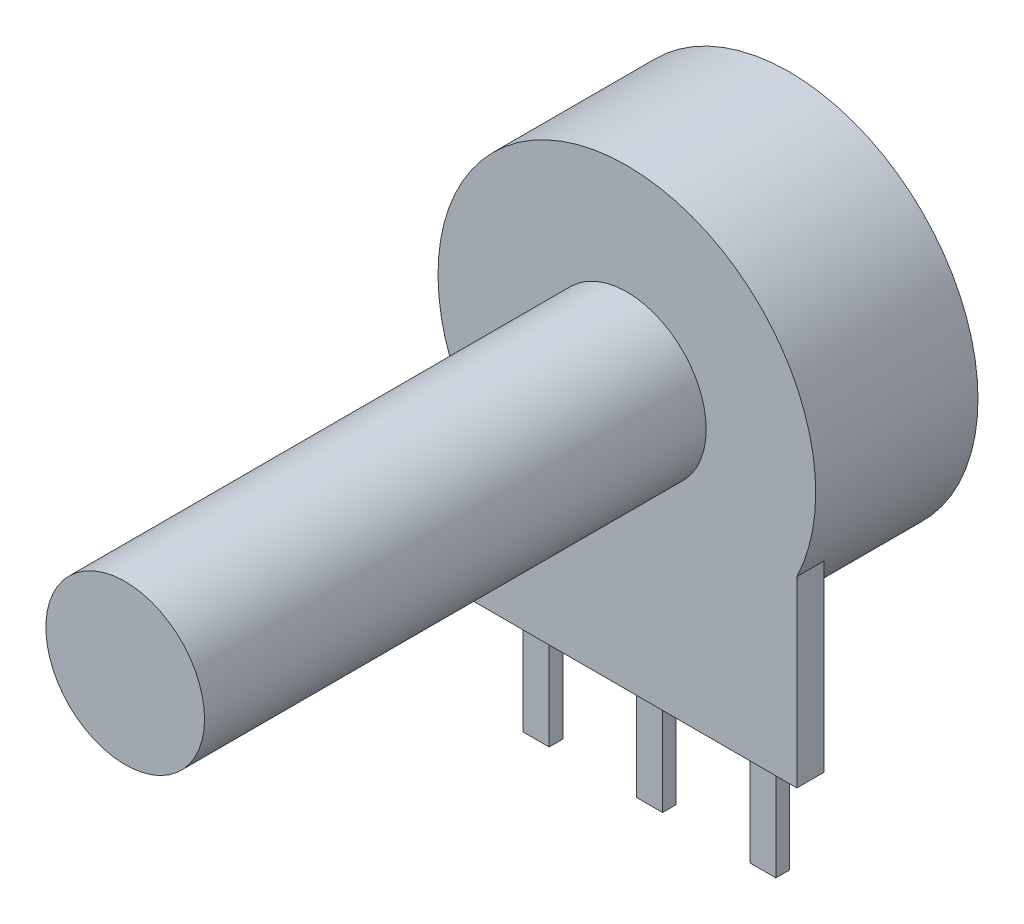
from build123d import *

# Parameters (mm, degrees)
SKETCH1_R           = 8.33
BOSS_EXTRUDE1_DEPTH = 7.16
SKETCH2_R           = 3.5
BOSS_EXTRUDE2_DEPTH = 22.13
SKETCH3_W           = 15
SKETCH3_H           = 11.20454244
BOSS_EXTRUDE3_DEPTH = 1.2
BOSS_EXTRUDE4_START = -0.2
SKETCH4_W           = 1.15
SKETCH4_H           = 4.9
BOSS_EXTRUDE4_DEPTH = 0.6
LPATTERN1_COUNT     = 2
LPATTERN1_PITCH     = 5
LPATTERN1_COL_COUNT = 2
LPATTERN1_COL_PITCH = 5


with BuildPart() as part:
    # Sketch1 → Boss-Extrude1 (new body)
    with BuildSketch(Plane.XY):
        Circle(SKETCH1_R)
    extrude(amount=BOSS_EXTRUDE1_DEPTH)

    # Sketch2 → Boss-Extrude2 (add)
    with BuildSketch(Plane.XY.offset(7.16)):
        Circle(SKETCH2_R)
    extrude(amount=BOSS_EXTRUDE2_DEPTH)

    # Sketch3 → Boss-Extrude3 (add)
    with BuildSketch(Plane.XY.offset(7.16)):
        with Locations((0, -6.09772878)):
            Rectangle(SKETCH3_W, SKETCH3_H)
    extrude(amount=-BOSS_EXTRUDE3_DEPTH)

    # Sketch4 → Boss-Extrude4 (add)
    with BuildSketch(Plane(origin=(0, 0, 5.96), x_dir=(-1, 0, 0), z_dir=(0, 0, -1)).offset(BOSS_EXTRUDE4_START)):
        with Locations((0, -14.15)):
            Rectangle(SKETCH4_W, SKETCH4_H)
    boss_extrude4 = extrude(amount=BOSS_EXTRUDE4_DEPTH)

    # LPattern1: Boss-Extrude4 ×2
    with Locations(*[(i * LPATTERN1_PITCH, 0, 0) for i in range(1, LPATTERN1_COUNT)]):
        add(boss_extrude4)

    # LPattern1 col: Boss-Extrude4 ×2
    with Locations(*[(-i * LPATTERN1_COL_PITCH, 0, 0) for i in range(1, LPATTERN1_COL_COUNT)]):
        add(boss_extrude4)


solid = part.part
